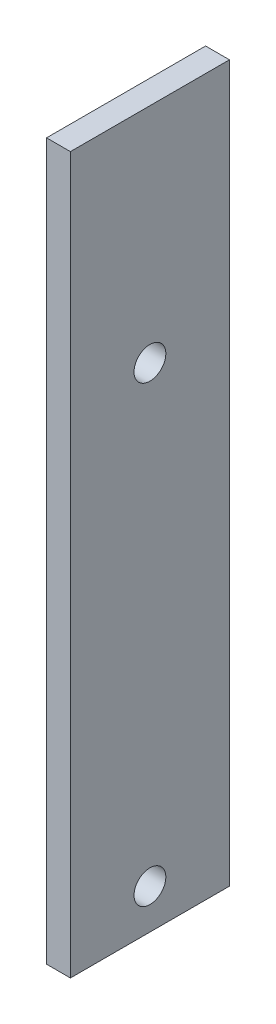
from build123d import *

# Parameters (mm, degrees)
SKETCH1_W           = 20
SKETCH1_H           = 90
BOSS_EXTRUDE1_DEPTH = 3
SKETCH2_R           = 2
CUT_EXTRUDE1_DEPTH  = 3


with BuildPart() as part:
    # Sketch1 → Boss-Extrude1 (new body)
    with BuildSketch(Plane(origin=(0, 0, 0), x_dir=(0, 0, -1), z_dir=(1, 0, 0))):
        Rectangle(SKETCH1_W, SKETCH1_H)
    extrude(amount=BOSS_EXTRUDE1_DEPTH)

    # Sketch2 → Cut-Extrude1 (cut)
    with BuildSketch(Plane(origin=(3, 0, 0), x_dir=(0, 0, -1), z_dir=(1, 0, 0))):
        with Locations((0, 17)):
            Circle(SKETCH2_R)
        with Locations((0, -40)):
            Circle(SKETCH2_R)
    extrude(amount=-CUT_EXTRUDE1_DEPTH, mode=Mode.SUBTRACT)


solid = part.part
